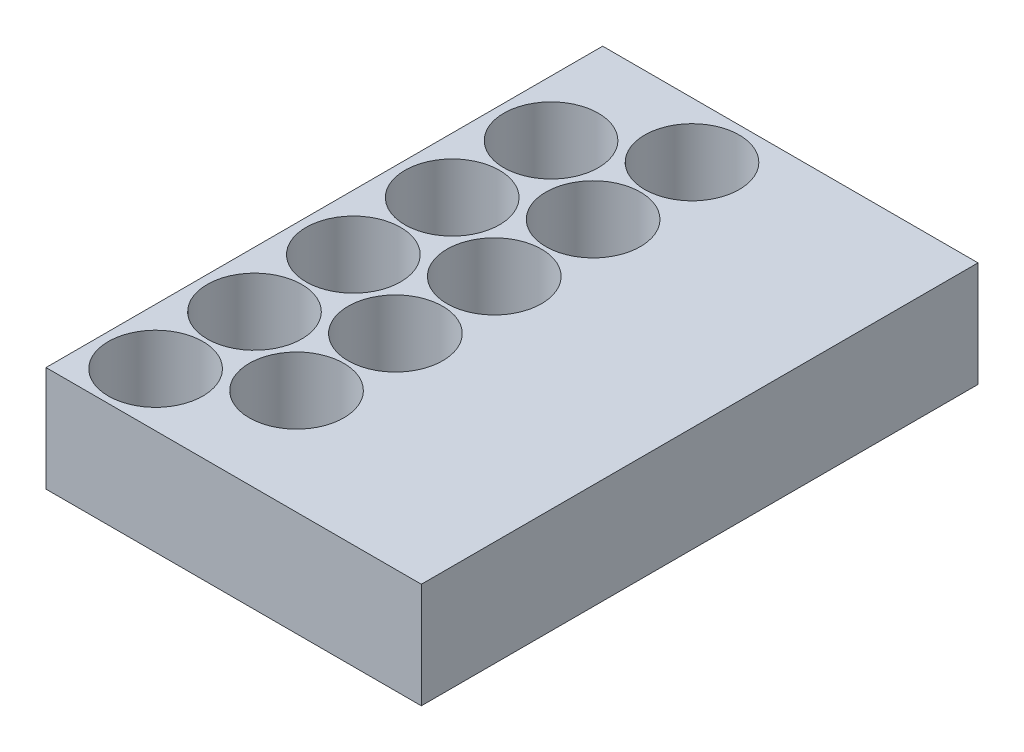
from build123d import *

# Parameters (mm, degrees)
SKETCH2_W           = 87.32
SKETCH2_H           = 129.5
BOSS_EXTRUDE1_DEPTH = 24.5
SKETCH3_R           = 11
CUT_EXTRUDE1_DEPTH  = 25.5
LPATTERN1_COUNT     = 5
LPATTERN1_PITCH     = 23


with BuildPart() as part:
    # Sketch2 → Boss-Extrude1 (new body)
    with BuildSketch(Plane(origin=(0, 0, 0), x_dir=(1, 0, 0), z_dir=(0, 1, 0))):
        Rectangle(SKETCH2_W, SKETCH2_H)
    extrude(amount=BOSS_EXTRUDE1_DEPTH)

    # Sketch3 → Cut-Extrude1 (cut, through all)
    with BuildSketch(Plane(origin=(0, 24.5, 0), x_dir=(1, 0, 0), z_dir=(0, 1, 0))):
        with Locations((-30.66, 39.75)):
            Circle(SKETCH3_R)
        with Locations((-9.875390309, 51.75)):
            Circle(SKETCH3_R)
    cut_extrude1 = extrude(amount=-CUT_EXTRUDE1_DEPTH, mode=Mode.SUBTRACT)

    # LPattern1: Cut-Extrude1 ×5
    with Locations(*[(0, 0, i * LPATTERN1_PITCH) for i in range(1, LPATTERN1_COUNT)]):
        add(cut_extrude1, mode=Mode.SUBTRACT)


solid = part.part
